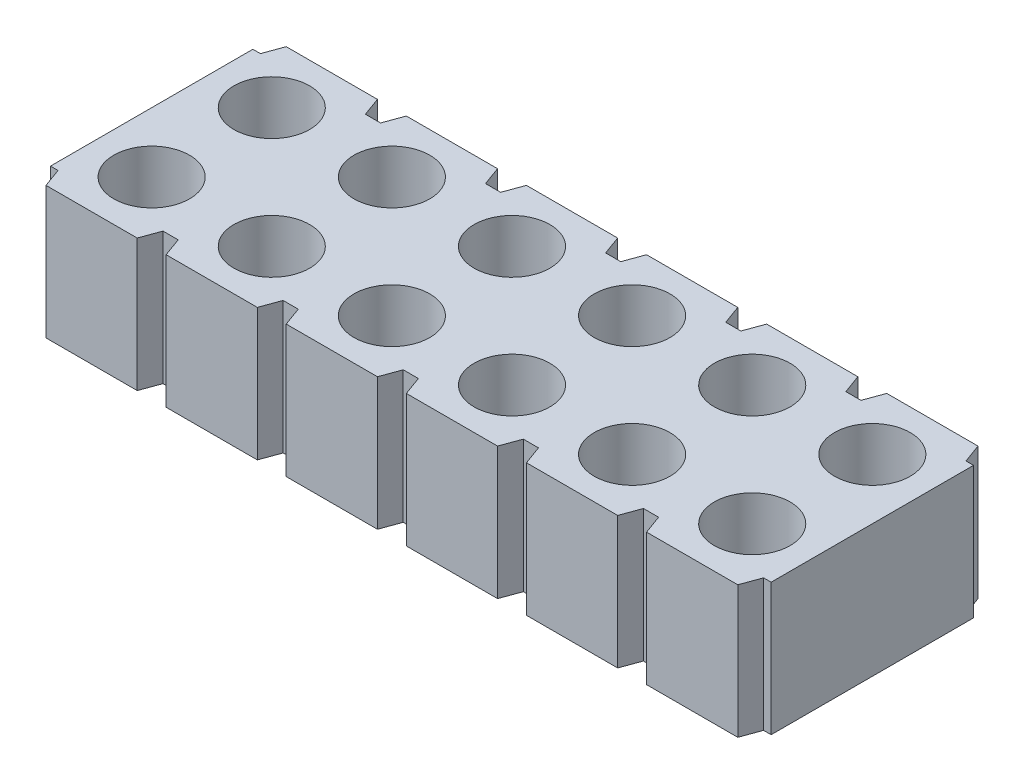
from build123d import *

# Parameters (mm, degrees)
EXTRUDE1_DEPTH       = 2.794
HOLE1_D              = 1.60274
EXTRUDE2_DEPTH       = 2.794
LPATTERN1_COUNT      = 6
LPATTERN1_PITCH      = 2.54
LPATTERN1_COUNT_DIR2 = 2
LPATTERN1_PITCH_DIR2 = 2.54
LPATTERN2_COUNT      = 35
LPATTERN2_PITCH      = 2.54


with BuildPart() as part:
    # Sketch1 → Extrude1 (new body)
    with BuildSketch(Plane(origin=(0, 0, 0), x_dir=(1, 0, 0), z_dir=(0, 1, 0))):
        Polygon((14.934373708, 0.40005), (14.774353708, 0.40005), (14.628747416, 0), (0, 0), (-0.145606292, 0.40005), (-0.305626292, 0.40005), (-0.305626292, 4.67995), (-0.145606292, 4.67995), (0, 5.08), (14.628747416, 5.08), (14.774353708, 4.67995), (14.934373708, 4.67995), align=None)
    extrude(amount=-EXTRUDE1_DEPTH)

    # Hole1 (through all)
    with Locations(Plane(origin=(0.964373708, 0, -1.27), x_dir=(0, 0, 1), z_dir=(0, 1, 0))):
        with Locations((0, 0)):
            hole1 = Hole(HOLE1_D / 2)

    # Sketch4 → Extrude2 (cut)
    with BuildSketch(Plane(origin=(0, 0, 0), x_dir=(1, 0, 0), z_dir=(0, 1, 0))):
        Polygon((1.928772816, 0), (2.5399746, 0), (2.394368308, 0.40005), (2.074379108, 0.40005), align=None)
        Polygon((2.074379108, 4.67995), (2.394368308, 4.67995), (2.5399746, 5.08), (1.928772816, 5.08), align=None)
    extrude2 = extrude(amount=-EXTRUDE2_DEPTH, mode=Mode.SUBTRACT)

    # LPattern1: Hole1 6 × 2
    with Locations(*[(i * LPATTERN1_PITCH, 0, -j * LPATTERN1_PITCH_DIR2) for i in range(LPATTERN1_COUNT) for j in range(LPATTERN1_COUNT_DIR2) if (i, j) != (0, 0)]):
        add(hole1, mode=Mode.SUBTRACT)

    # LPattern2: Extrude2 ×35
    with Locations(*[(i * LPATTERN2_PITCH, 0, 0) for i in range(1, LPATTERN2_COUNT)]):
        add(extrude2, mode=Mode.SUBTRACT)


solid = part.part
